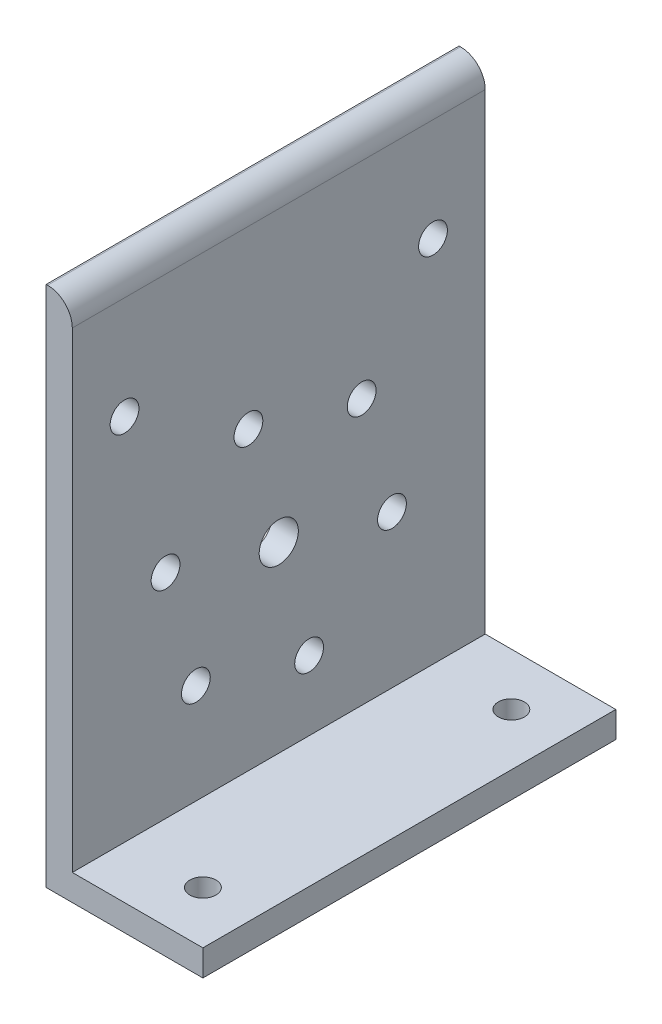
from build123d import *

# Parameters (mm, degrees)
BOSS_EXTRUDE1_DEPTH     = 100.4
SKETCH2_R               = 4.7625
SKETCH2_R_2             = 3.5
CUT_EXTRUDE1_DEPTH      = 1
CUT_EXTRUDE1_DEPTH_BACK = 39.1
SKETCH3_R               = 3.175
CUT_EXTRUDE2_DEPTH      = 7.35
SKETCH5_R               = 3.5
CUT_EXTRUDE4_DEPTH      = 10


with BuildPart() as part:
    # Sketch1 → Boss-Extrude1 (new body)
    with BuildSketch(Plane.XY):
        with BuildLine():
            Line((0, 6.35), (0, 0))
            Line((0, 0), (38.1, 0))
            Line((38.1, 0), (38.1, 0.35))
            Line((38.1, 0.35), (38.1, 6.35))
            Line((38.1, 6.35), (32.1, 6.35))
            Line((32.1, 6.35), (6.35, 6.35))
            Line((6.35, 6.35), (6.35, 37.75))
            Line((6.35, 37.75), (6.35, 121))
            ThreePointArc((6.35, 121), (4.592640687, 125.242640687), (0.35, 127))
            Line((0.35, 127), (0, 127))
            Line((0, 127), (0, 6.35))
        make_face()
    extrude(amount=BOSS_EXTRUDE1_DEPTH)

    # Sketch2 → Cut-Extrude1 (cut, two sides)
    with BuildSketch(Plane.ZY) as cut_extrude1_sk:
        with Locations((50.2, 50.8)):
            Circle(SKETCH2_R)
        with Locations((57.576342785, 78.328886049)):
            Circle(SKETCH2_R_2)
        with Locations((30.047456736, 70.952543264)):
            Circle(SKETCH2_R_2)
        with Locations((22.671113951, 43.423657215)):
            Circle(SKETCH2_R_2)
        with Locations((42.823657215, 23.271113951)):
            Circle(SKETCH2_R_2)
        with Locations((70.352543264, 30.647456736)):
            Circle(SKETCH2_R_2)
        with Locations((77.728886049, 58.176342785)):
            Circle(SKETCH2_R_2)
    extrude(amount=CUT_EXTRUDE1_DEPTH, mode=Mode.SUBTRACT)
    extrude(cut_extrude1_sk.sketch, amount=-CUT_EXTRUDE1_DEPTH_BACK, mode=Mode.SUBTRACT)

    # Sketch3 → Cut-Extrude2 (cut, through all)
    with BuildSketch(Plane(origin=(0, 6.35, 0), x_dir=(1, 0, 0), z_dir=(0, 1, 0))):
        with Locations((25.4, -12.7)):
            Circle(SKETCH3_R)
        with Locations((25.4, -87.7)):
            Circle(SKETCH3_R)
    extrude(amount=-CUT_EXTRUDE2_DEPTH, mode=Mode.SUBTRACT)

    # Sketch5 → Cut-Extrude4 (cut)
    with BuildSketch(Plane(origin=(6.35, 0, 0), x_dir=(0, 0, -1), z_dir=(1, 0, 0))):
        with Locations((-87.7, 96)):
            Circle(SKETCH5_R)
        with Locations((-12.7, 96)):
            Circle(SKETCH5_R)
    extrude(amount=-CUT_EXTRUDE4_DEPTH, mode=Mode.SUBTRACT)


solid = part.part
